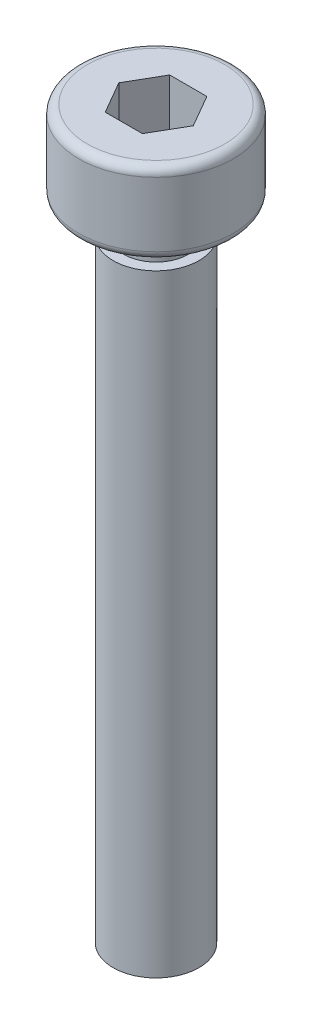
from build123d import *

# Parameters (mm, degrees)
CUT_EXTRUDE_1_DEPTH = 2.8


with BuildPart() as part:
    # 草图1 → 旋转1 (revolve)
    with BuildSketch(Plane.XY):
        with BuildLine():
            Line((0, 33.8), (-3.2, 33.8))
            ThreePointArc((-3.2, 33.8), (-3.482842712, 33.682842712), (-3.6, 33.4))
            Line((-3.6, 33.4), (-3.6, 30.4))
            ThreePointArc((-3.6, 30.4), (-3.482842712, 30.117157288), (-3.2, 30))
            Line((-3.2, 30), (-1.5, 30))
            Line((-1.5, 30), (-1.5, 28.5))
            Line((-1.5, 28.5), (-2, 28.5))
            Line((-2, 28.5), (-2, 0))
            Line((-2, 0), (0, 0))
            Line((0, 0), (0, 33.8))
        make_face()
    revolve(axis=Axis((0, 0, 0), (0, 1, 0)))

    # 草图2 → 切除-拉伸1 (cut)
    with BuildSketch(Plane(origin=(0, 33.8, 0), x_dir=(1, 0, 0), z_dir=(0, 1, 0))):
        Polygon((-0.866025404, 1.5), (-1.732050808, 0), (-0.866025404, -1.5), (0.866025404, -1.5), (1.732050808, 0), (0.866025404, 1.5), align=None)
    extrude(amount=-CUT_EXTRUDE_1_DEPTH, mode=Mode.SUBTRACT)


solid = part.part
